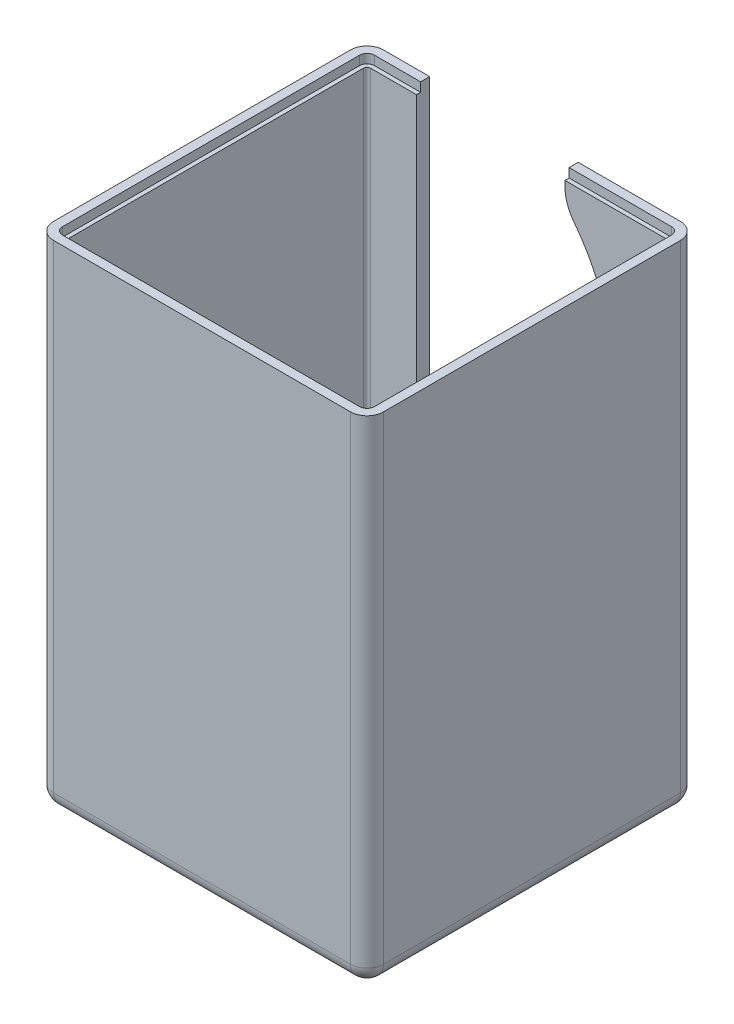
from build123d import *

# Parameters (mm, degrees)
SKETCH1_W           = 200
SKETCH1_H           = 200
BOSS_EXTRUDE1_DEPTH = 300
FILLET1_R           = 10
SHELL1_T            = -8
CUT_EXTRUDE1_DEPTH  = 44
FILLET2_R           = 25
FILLET3_R           = 25
CUT_EXTRUDE2_DEPTH  = 5.5


with BuildPart() as part:
    # Sketch1 → Boss-Extrude1 (new body)
    with BuildSketch(Plane(origin=(0, 0, 0), x_dir=(1, 0, 0), z_dir=(0, 1, 0))):
        Rectangle(SKETCH1_W, SKETCH1_H)
    extrude(amount=BOSS_EXTRUDE1_DEPTH)

    # Fillet1
    fillet1_edges = [part.edges().sort_by_distance(p)[0] for p in [
        (0, 0, -100),
        (100, 0, 0),
        (0, 0, 100),
        (-100, 0, 0),
        (-100, 150, -100),
        (100, 150, -100),
        (100, 150, 100),
        (-100, 150, 100),
    ]]
    fillet(fillet1_edges, radius=FILLET1_R)

    # Shell1
    shell1_openings = [part.faces().sort_by_distance(p)[0] for p in [
        (0, 300, 0),
    ]]
    offset(amount=SHELL1_T, openings=shell1_openings, kind=Kind.INTERSECTION)

    # Sketch2 → Cut-Extrude1 (cut)
    with BuildSketch(Plane(origin=(0, 0, -100), x_dir=(-1, 0, 0), z_dir=(0, 0, -1))):
        with BuildLine():
            Line((62, 100), (-28, 100))
            Line((-28, 100), (-28, 130))
            ThreePointArc((-28, 130), (-57.029416855, 206), (-28, 282))
            Line((-28, 282), (-28, 300))
            Line((-28, 300), (62, 300))
            Line((62, 300), (62, 100))
        make_face()
    extrude(amount=-CUT_EXTRUDE1_DEPTH, mode=Mode.SUBTRACT)

    # Fillet2
    fillet2_edges = [part.edges().sort_by_distance(p)[0] for p in [
        (28, 130, -96),
    ]]
    fillet(fillet2_edges, radius=FILLET2_R)

    # Fillet3
    fillet3_edges = [part.edges().sort_by_distance(p)[0] for p in [
        (28, 282, -96),
    ]]
    fillet(fillet3_edges, radius=FILLET3_R)

    # Sketch3 → Cut-Extrude2 (cut)
    with BuildSketch(Plane(origin=(0, 300, 0), x_dir=(1, 0, 0), z_dir=(0, 1, 0))):
        with BuildLine():
            Line((28, 92), (90, 92))
            ThreePointArc((90, 92), (91.414213562, 91.414213562), (92, 90))
            Line((92, 90), (92, -90))
            ThreePointArc((92, -90), (91.414213562, -91.414213562), (90, -92))
            Line((90, -92), (-90, -92))
            ThreePointArc((-90, -92), (-91.414213562, -91.414213562), (-92, -90))
            Line((-92, -90), (-92, 90))
            ThreePointArc((-92, 90), (-91.414213562, 91.414213562), (-90, 92))
            Line((-90, 92), (-62, 92))
            Line((-62, 92), (-62, 94.5))
            Line((-62, 94.5), (-90, 94.5))
            ThreePointArc((-90, 94.5), (-93.181980515, 93.181980515), (-94.5, 90))
            Line((-94.5, 90), (-94.5, -90))
            ThreePointArc((-94.5, -90), (-93.181980515, -93.181980515), (-90, -94.5))
            Line((-90, -94.5), (90, -94.5))
            ThreePointArc((90, -94.5), (93.181980515, -93.181980515), (94.5, -90))
            Line((94.5, -90), (94.5, 90))
            ThreePointArc((94.5, 90), (93.181980515, 93.181980515), (90, 94.5))
            Line((90, 94.5), (28, 94.5))
            Line((28, 94.5), (28, 92))
        make_face()
    extrude(amount=-CUT_EXTRUDE2_DEPTH, mode=Mode.SUBTRACT)


solid = part.part
